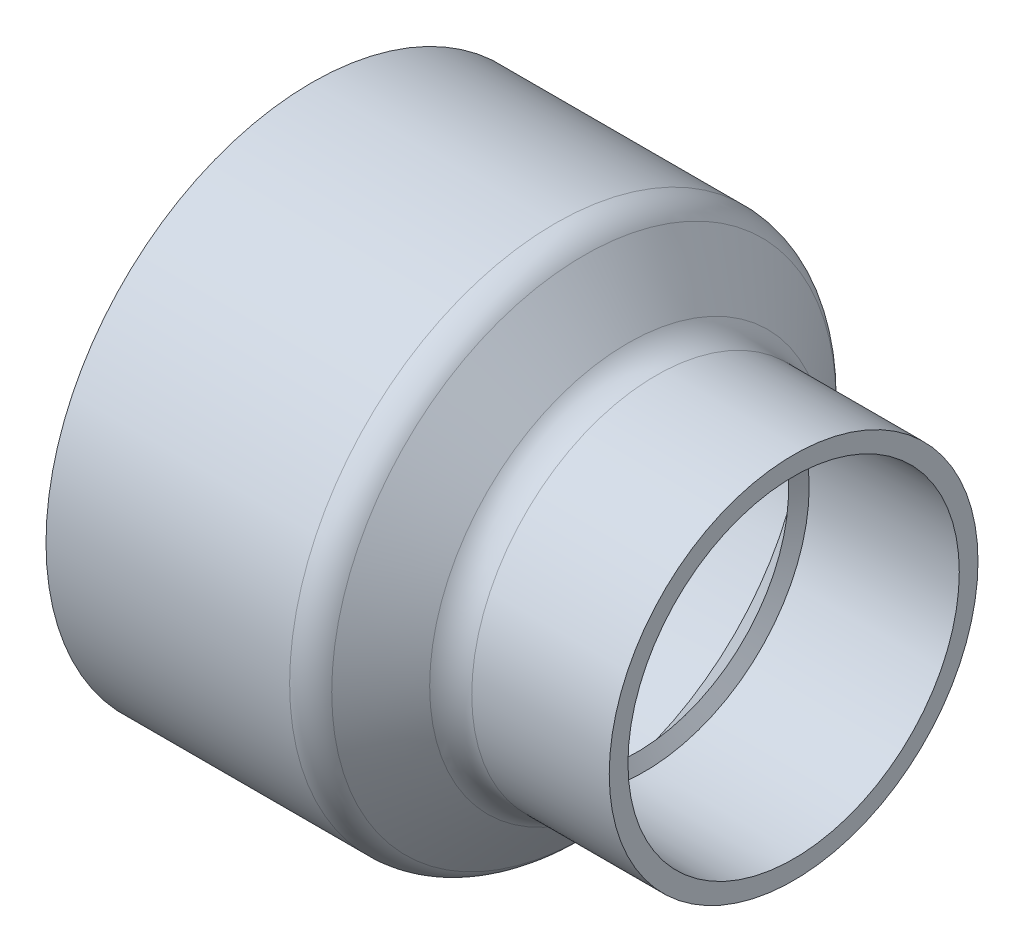
from build123d import *

# Parameters (mm, degrees)
FILLET1_R = 12.7


with BuildPart() as part:
    # Sketch1 → Revolve1 (revolve)
    with BuildSketch(Plane.XY):
        Polygon((3.6957, -83.9978), (29.197852081, -52.50526491), (31.8135, -57.0357), (83.4517, -57.3786), (83.4517, -63.8556), (29.778956153, -63.8556), (6.978757892, -92.0115), (-83.4517, -92.0115), (-83.4517, -84.4169), align=None)
    revolve(axis=Axis((-83.4517, 0, 0), (1, 0, 0)))

    # Fillet1
    fillet1_edges = [part.edges().sort_by_distance(p)[0] for p in [
        (6.978757892, 92.0115, 0),
        (29.778956153, 63.8556, 0),
    ]]
    fillet(fillet1_edges, radius=FILLET1_R)


solid = part.part
